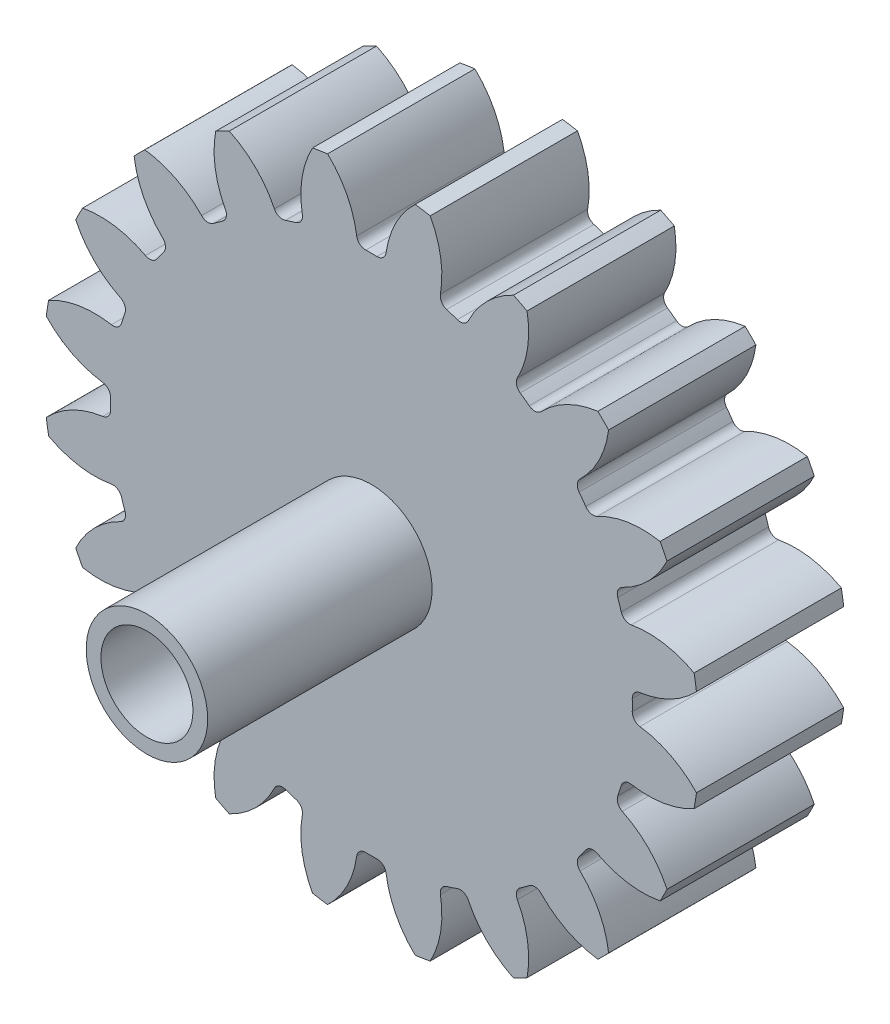
from build123d import *

# Parameters (mm, degrees)
SKETCH1_R                = 22.275
BOSS_EXTRUDE1_DEPTH      = 10
CUT_EXTRUDE1_DEPTH       = 11
FILLET1_R                = 0.6075
CIRPATTERN5_COUNT        = 20
FILLET1_OF_CIRPATTERN5_R = 0.6075
SKETCH3_R                = 2.625
CUT_EXTRUDE2_DEPTH       = 10
SKETCH4_R                = 4.125
SKETCH4_R_2              = 2.625
BOSS_EXTRUDE2_DEPTH      = 1
SKETCH6_R                = 4.125
SKETCH6_R_2              = 3.125
BOSS_EXTRUDE4_DEPTH      = 15.24
BOSS_EXTRUDE5_DEPTH      = 11


with BuildPart() as part:
    # Sketch1 → Boss-Extrude1 (new body)
    with BuildSketch(Plane.XY):
        Circle(SKETCH1_R)
    extrude(amount=BOSS_EXTRUDE1_DEPTH)

    # Sketch2 → Cut-Extrude1 (cut, through all)
    with BuildSketch(Plane.XY):
        with BuildLine():
            ThreePointArc((-3.116364363, 22.207406381), (-1.57918473, 20.167679259), (-0.945185984, 17.69352212))
            ThreePointArc((-0.945185984, 17.69352212), (0, 17.71875), (0.945185984, 17.69352212))
            ThreePointArc((0.945185984, 17.69352212), (1.57918473, 20.167679259), (3.116364363, 22.207406381))
            ThreePointArc((3.116364363, 22.207406381), (0, 22.425), (-3.116364363, 22.207406381))
        make_face()
    cut_extrude1 = extrude(amount=CUT_EXTRUDE1_DEPTH, mode=Mode.SUBTRACT)

    # Fillet1
    fillet1_edges = [part.edges().sort_by_distance(p)[0] for p in [
        (0.945185984, 17.69352212, 5),
        (-0.945185984, 17.69352212, 5),
    ]]
    fillet(fillet1_edges, radius=FILLET1_R)

    # CirPattern5: Cut-Extrude1 ×20 about axis
    cirpattern5_axis = Axis((0, 0, 0), (0, 0, 1))
    for i in range(1, CIRPATTERN5_COUNT):
        add(cut_extrude1.rotate(cirpattern5_axis, i * 360 / CIRPATTERN5_COUNT), mode=Mode.SUBTRACT)

    # Fillet1 of CirPattern5
    fillet1_of_cirpattern5_edges = [part.edges().sort_by_distance(p)[0] for p in [
        (-4.568673736, 17.11961804, 5),
        (-6.366524315, 16.535460977, 5),
        (-9.63531984, 14.869926468, 5),
        (-11.164662887, 13.758793704, 5),
        (-13.758793704, 11.164662887, 5),
        (-14.869926468, 9.63531984, 5),
        (-16.535460977, 6.366524315, 5),
        (-17.11961804, 4.568673736, 5),
        (-17.69352212, 0.945185984, 5),
        (-17.69352212, -0.945185984, 5),
        (-17.11961804, -4.568673736, 5),
        (-16.535460977, -6.366524315, 5),
        (-14.869926468, -9.63531984, 5),
        (-13.758793704, -11.164662887, 5),
        (-11.164662887, -13.758793704, 5),
        (-9.63531984, -14.869926468, 5),
        (-6.366524315, -16.535460977, 5),
        (-4.568673736, -17.11961804, 5),
        (-0.945185984, -17.69352212, 5),
        (0.945185984, -17.69352212, 5),
        (4.568673736, -17.11961804, 5),
        (6.366524315, -16.535460977, 5),
        (9.63531984, -14.869926468, 5),
        (11.164662887, -13.758793704, 5),
        (13.758793704, -11.164662887, 5),
        (14.869926468, -9.63531984, 5),
        (16.535460977, -6.366524315, 5),
        (17.11961804, -4.568673736, 5),
        (17.69352212, -0.945185984, 5),
        (17.69352212, 0.945185984, 5),
        (17.11961804, 4.568673736, 5),
        (16.535460977, 6.366524315, 5),
        (14.869926468, 9.63531984, 5),
        (13.758793704, 11.164662887, 5),
        (11.164662887, 13.758793704, 5),
        (9.63531984, 14.869926468, 5),
        (6.366524315, 16.535460977, 5),
        (4.568673736, 17.11961804, 5),
    ]]
    fillet(fillet1_of_cirpattern5_edges, radius=FILLET1_OF_CIRPATTERN5_R)

    # Sketch3 → Cut-Extrude2 (cut)
    with BuildSketch(Plane.XY.offset(10)):
        Circle(SKETCH3_R)
    extrude(amount=-CUT_EXTRUDE2_DEPTH, mode=Mode.SUBTRACT)

    # Sketch4 → Boss-Extrude2 (add)
    with BuildSketch(Plane.XY.offset(10)):
        Circle(SKETCH4_R)
        Circle(SKETCH4_R_2, mode=Mode.SUBTRACT)
    extrude(amount=BOSS_EXTRUDE2_DEPTH)

    # Sketch6 → Boss-Extrude4 (add)
    with BuildSketch(Plane.XY.offset(10)):
        Circle(SKETCH6_R)
        Circle(SKETCH6_R_2, mode=Mode.SUBTRACT)
    extrude(amount=BOSS_EXTRUDE4_DEPTH)

    # Sketch5 → Boss-Extrude5 (add)
    with BuildSketch(Plane(origin=(0, 0, 0), x_dir=(-1, 0, 0), z_dir=(0, 0, -1))):
        with BuildLine():
            Line((0.517988308, -2.573385535), (-2.521923501, -0.728372746))
            ThreePointArc((-2.521923501, -0.728372746), (-1.361968103, -2.244029387), (0.517988308, -2.573385535))
        make_face()
    extrude(amount=-BOSS_EXTRUDE5_DEPTH)


solid = part.part
